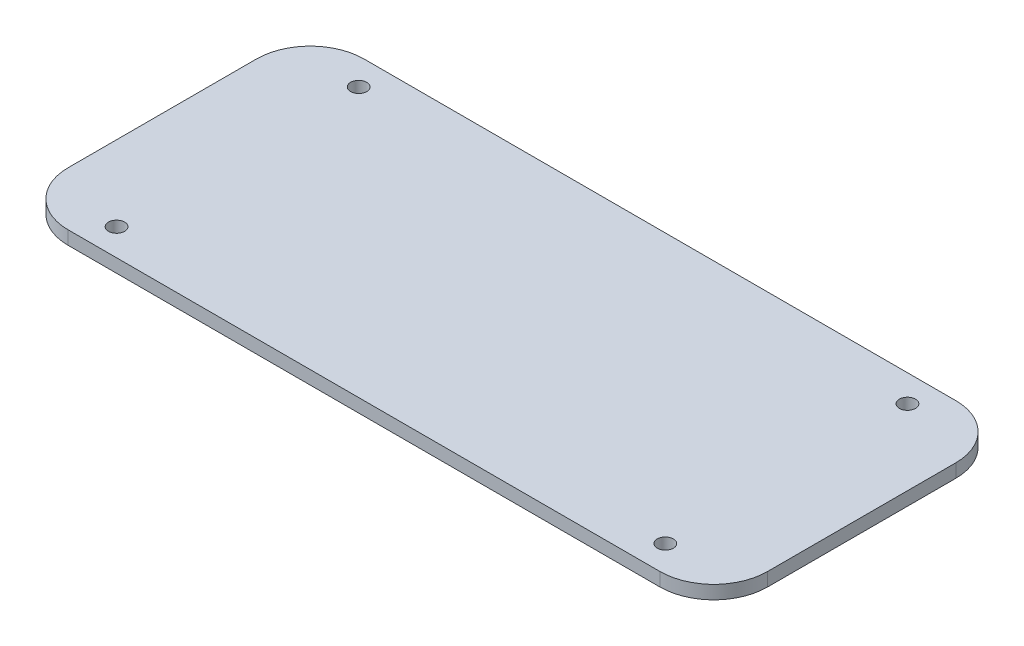
from build123d import *

# Parameters (mm, degrees)
BOSS_EXTRUDE1_DEPTH = 2.5
SKETCH2_R           = 1.5
CUT_EXTRUDE1_DEPTH  = 3.5


with BuildPart() as part:
    # Sketch1 → Boss-Extrude1 (new body)
    with BuildSketch(Plane(origin=(0, 0, 0), x_dir=(1, 0, 0), z_dir=(0, 1, 0))):
        with BuildLine():
            Line((10, 0), (120, 0))
            ThreePointArc((120, 0), (127.071067812, 2.928932188), (130, 10))
            Line((130, 10), (130, 45))
            ThreePointArc((130, 45), (127.071067812, 52.071067812), (120, 55))
            Line((120, 55), (10, 55))
            ThreePointArc((10, 55), (2.928932188, 52.071067812), (0, 45))
            Line((0, 45), (0, 10))
            ThreePointArc((0, 10), (2.928932188, 2.928932188), (10, 0))
        make_face()
    extrude(amount=BOSS_EXTRUDE1_DEPTH)

    # Sketch2 → Cut-Extrude1 (cut, through all)
    with BuildSketch(Plane(origin=(0, 2.5, 0), x_dir=(1, 0, 0), z_dir=(0, 1, 0))):
        with Locations((14, 5)):
            Circle(SKETCH2_R)
        with Locations((14, 50)):
            Circle(SKETCH2_R)
        with Locations((116, 5)):
            Circle(SKETCH2_R)
        with Locations((116, 50)):
            Circle(SKETCH2_R)
    extrude(amount=-CUT_EXTRUDE1_DEPTH, mode=Mode.SUBTRACT)


solid = part.part
